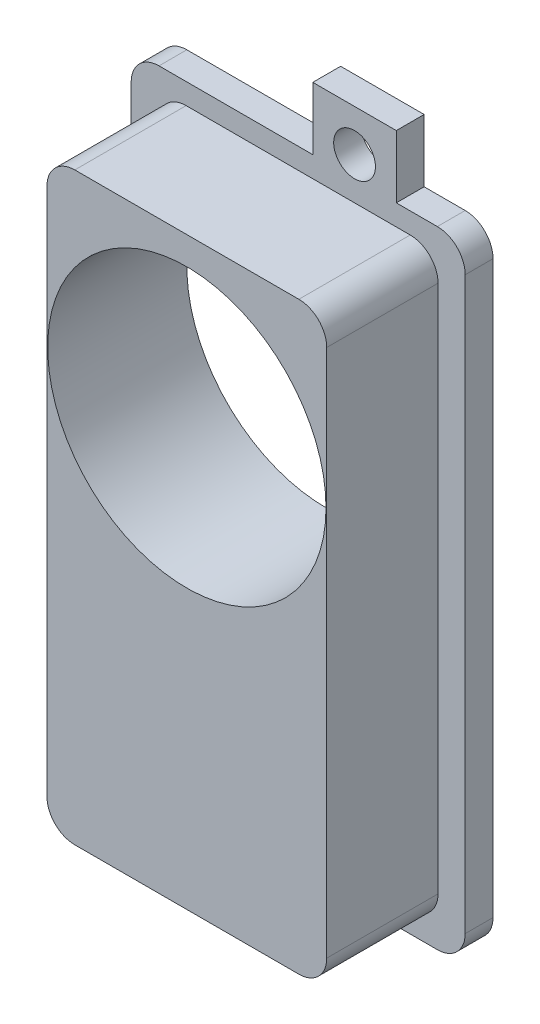
from build123d import *

# Parameters (mm, degrees)
SKETCH1_R           = 1.5
BOSS_EXTRUDE1_DEPTH = 2
FILLET1_R           = 2
SKETCH3_W           = 20.1
SKETCH3_H           = 42
BOSS_EXTRUDE2_DEPTH = 8
FILLET2_R           = 2
SKETCH5_R           = 10
CUT_EXTRUDE3_DEPTH  = 11


with BuildPart() as part:
    # Sketch1 → Boss-Extrude1 (new body)
    with BuildSketch(Plane.XY):
        Polygon((1.05, 22.5), (1.05, 27), (7.05, 27), (7.05, 22.5), (12, 22.5), (12, -22.5), (-1.05, -22.5), (-1.05, -27), (-7.05, -27), (-7.05, -22.5), (-12, -22.5), (-12, 22.5), align=None)
        with Locations((4.05, 24)):
            Circle(SKETCH1_R, mode=Mode.SUBTRACT)
        with Locations((-4.05, -24)):
            Circle(SKETCH1_R, mode=Mode.SUBTRACT)
    extrude(amount=BOSS_EXTRUDE1_DEPTH)

    # Fillet1
    fillet1_edges = [part.edges().sort_by_distance(p)[0] for p in [
        (12, 22.5, 1),
        (12, -22.5, 1),
        (-12, -22.5, 1),
        (-12, 22.5, 1),
    ]]
    fillet(fillet1_edges, radius=FILLET1_R)

    # Sketch3 → Boss-Extrude2 (add)
    with BuildSketch(Plane.XY.offset(2)):
        Rectangle(SKETCH3_W, SKETCH3_H)
    extrude(amount=BOSS_EXTRUDE2_DEPTH)

    # Fillet2
    fillet2_edges = [part.edges().sort_by_distance(p)[0] for p in [
        (-10.05, 21, 6),
        (-10.05, -21, 6),
        (10.05, -21, 6),
        (10.05, 21, 6),
    ]]
    fillet(fillet2_edges, radius=FILLET2_R)

    # Sketch5 → Cut-Extrude3 (cut, through all)
    with BuildSketch(Plane.XY.offset(10)):
        with Locations((0, 9)):
            Circle(SKETCH5_R)
    extrude(amount=-CUT_EXTRUDE3_DEPTH, mode=Mode.SUBTRACT)


solid = part.part
